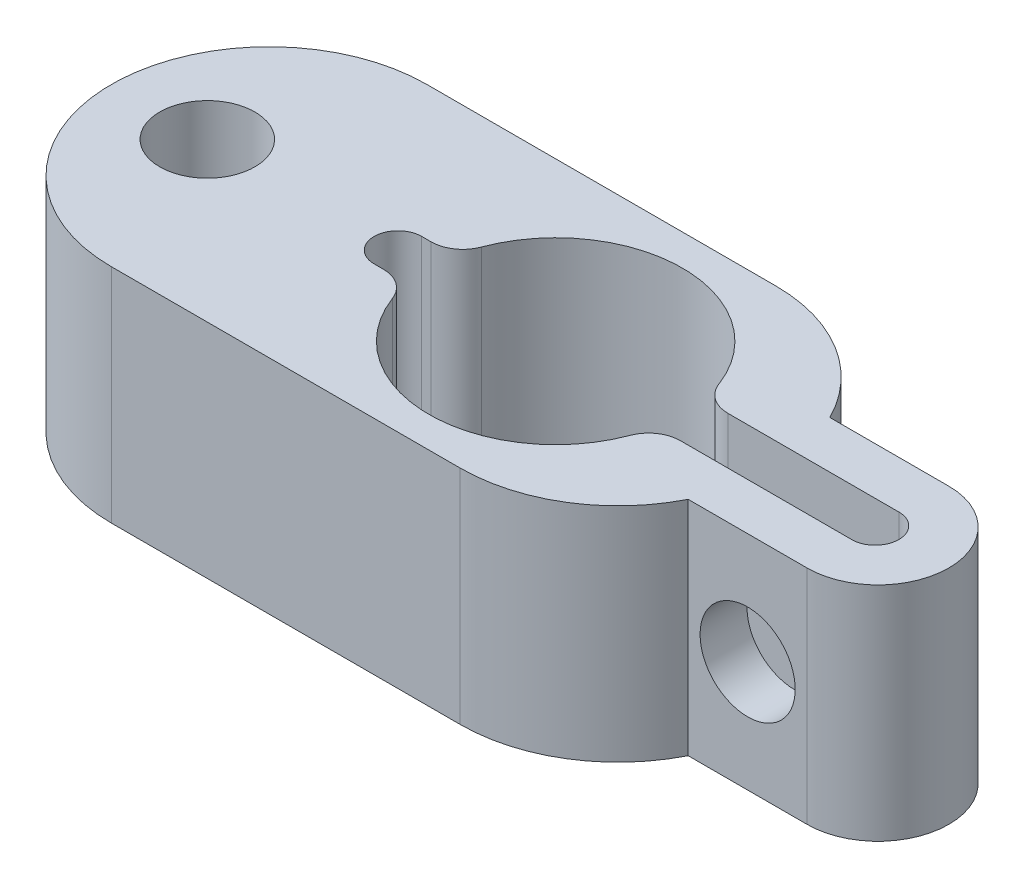
from build123d import *

# Parameters (mm, degrees)
BOSS_EXTRUDE2_DEPTH = 7
SKETCH2_R           = 1.5
CUT_EXTRUDE4_DEPTH  = 8
SKETCH4_R           = 1.5
CUT_EXTRUDE5_DEPTH  = 8.20758232


with BuildPart() as part:
    # Sketch1 → Boss-Extrude2 (new body)
    with BuildSketch(Plane(origin=(0, 0, 0), x_dir=(1, 0, 0), z_dir=(0, 1, 0))):
        with BuildLine():
            Line((-19.513780389, 2.233669643), (-15.763780389, 2.233669643))
            ThreePointArc((-15.763780389, 2.233669643), (-13.530110746, 0), (-15.763780389, -2.233669643))
            Line((-15.763780389, -2.233669643), (-19.513780389, -2.233669643))
            ThreePointArc((-19.513780389, -2.233669643), (-21.347407319, -4.233785839), (-23.957936917, -4.973912677))
            Line((-23.957936917, -4.973912677), (-34.957936917, -4.973912677))
            ThreePointArc((-34.957936917, -4.973912677), (-39.931849593, 0), (-34.957936917, 4.973912677))
            Line((-34.957936917, 4.973912677), (-23.957936917, 4.973912677))
            ThreePointArc((-23.957936917, 4.973912677), (-21.347407319, 4.233785839), (-19.513780389, 2.233669643))
        make_face()
    extrude(amount=BOSS_EXTRUDE2_DEPTH)

    # Sketch2 → Cut-Extrude4 (cut, through all)
    with BuildSketch(Plane(origin=(0, 0, 0), x_dir=(1, 0, 0), z_dir=(0, 1, 0))):
        with Locations((-36.918050981, 0.013343653)):
            Circle(SKETCH2_R)
        with BuildLine():
            Line((-15.763780389, -0.754616632), (-21.237726657, -0.754616632))
            ThreePointArc((-21.237726657, -0.754616632), (-21.807814369, -0.933032796), (-22.174476357, -1.404616632))
            ThreePointArc((-22.174476357, -1.404616632), (-25.917504746, -4.002240599), (-29.661243101, -1.405639951))
            ThreePointArc((-29.661243101, -1.405639951), (-30.027921677, -0.934234264), (-30.597897087, -0.755896014))
            Line((-30.597897087, -0.755896014), (-30.890644095, -0.755896014))
            ThreePointArc((-30.890644095, -0.755896014), (-31.640644095, -0.005896014), (-30.890644095, 0.744103986))
            Line((-30.890644095, 0.744103986), (-30.597897087, 0.744103986))
            ThreePointArc((-30.597897087, 0.744103986), (-30.027921677, 0.922442235), (-29.661243101, 1.393847922))
            ThreePointArc((-29.661243101, 1.393847922), (-25.917504746, 3.99044857), (-22.174476357, 1.392824603))
            ThreePointArc((-22.174476357, 1.392824603), (-21.807928303, 0.920033725), (-21.237080152, 0.74108938))
            Line((-21.237080152, 0.74108938), (-15.843921166, 0.74108938))
            ThreePointArc((-15.843921166, 0.74108938), (-15.094995432, 0.031217246), (-15.763780389, -0.754616632))
        make_face()
    extrude(amount=CUT_EXTRUDE4_DEPTH, mode=Mode.SUBTRACT)

    # Sketch4 → Cut-Extrude5 (cut, through all)
    with BuildSketch(Plane(origin=(0, 0, -2.233669643), x_dir=(-1, 0, 0), z_dir=(0, 0, -1))):
        with Locations((17.638780389, 3.5)):
            Circle(SKETCH4_R)
    extrude(amount=-CUT_EXTRUDE5_DEPTH, mode=Mode.SUBTRACT)


solid = part.part
